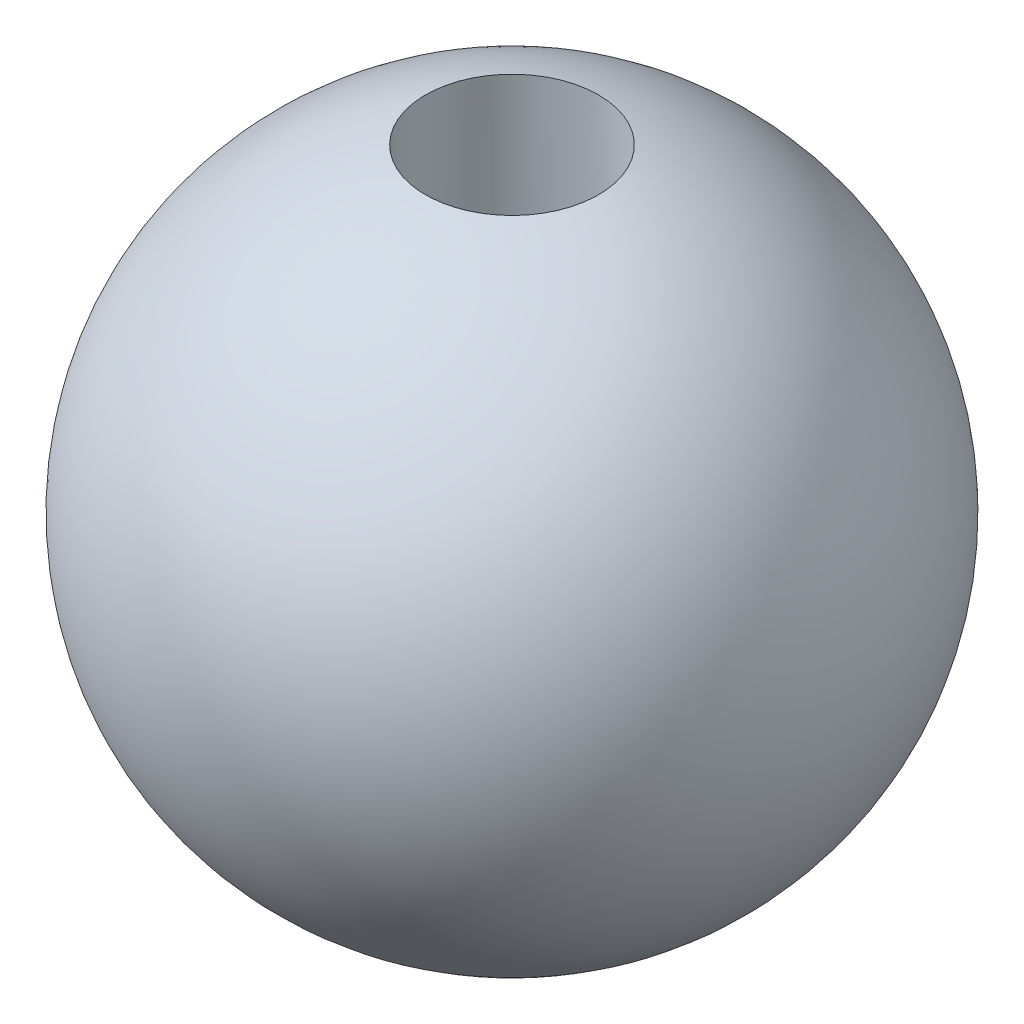
from build123d import *

# Parameters (mm, degrees)
SKETCH4_R          = 4.75
SKETCH3_R          = 4.25
SKETCH7_R          = 5
CUT_EXTRUDE4_DEPTH = 3
SKETCH8_R          = 3
CUT_EXTRUDE5_DEPTH = 2.5
CUT_EXTRUDE6_DEPTH = 7


with BuildPart() as part:
    # Sketch2 → Revolve1 (revolve)
    with BuildSketch(Plane.XY):
        with BuildLine():
            Line((0, 0), (32.5, 0))
            ThreePointArc((32.5, 0), (16.25, 16.25), (0, 0))
        make_face()
    revolve(axis=Axis((0, 0, 0), (1, 0, 0)))

    # Sketch4 → Cut-Loft1 section 0
    with BuildSketch(Plane(origin=(0, 0, 0), x_dir=(1, 0, 0), z_dir=(0, 1, 0))):
        with Locations((16.25, 0)):
            Circle(SKETCH4_R)
    # Sketch3 → Cut-Loft1 section 1
    with BuildSketch(Plane(origin=(0, 16.25, 0), x_dir=(1, 0, 0), z_dir=(0, 1, 0))):
        with Locations((16.25, 0)):
            Circle(SKETCH3_R)
    loft(mode=Mode.SUBTRACT)

    # Sketch7 → Cut-Extrude4 (cut)
    with BuildSketch(Plane(origin=(0, -17, 0), x_dir=(1, 0, 0), z_dir=(0, 1, 0))):
        with Locations((16.25, 0)):
            Circle(SKETCH7_R)
    extrude(amount=CUT_EXTRUDE4_DEPTH, mode=Mode.SUBTRACT)

    # Sketch8 → Cut-Extrude5 (cut)
    with BuildSketch(Plane.XZ.offset(14)):
        with Locations((16.25, 0)):
            Circle(SKETCH8_R)
    extrude(amount=-CUT_EXTRUDE5_DEPTH, mode=Mode.SUBTRACT)

    # Sketch9 → Cut-Extrude6 (cut)
    with BuildSketch(Plane.XZ.offset(11.5)):
        with BuildLine():
            Line((14.25, 2.236067977), (14.25, -2.236067977))
            ThreePointArc((14.25, -2.236067977), (16.25, -3), (18.25, -2.236067977))
            Line((18.25, -2.236067977), (18.25, 2.236067977))
            ThreePointArc((18.25, 2.236067977), (16.25, 3), (14.25, 2.236067977))
        make_face()
    extrude(amount=-CUT_EXTRUDE6_DEPTH, mode=Mode.SUBTRACT)


solid = part.part
